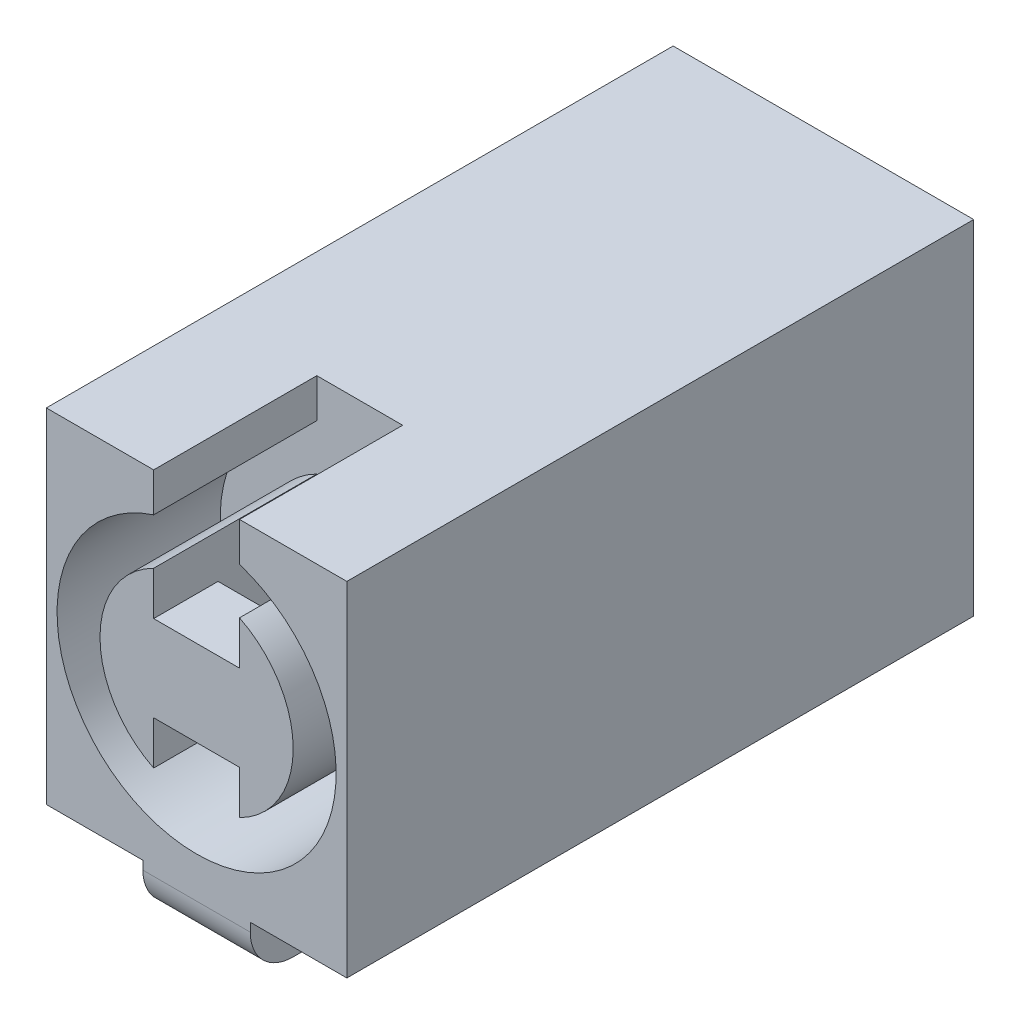
from build123d import *

# Parameters (mm, degrees)
SZKIC1_W                    = 7
SZKIC1_H                    = 14.6
DODANIE_WYCI_GNI_CIE1_DEPTH = 8
SZKIC2_W                    = 2
SZKIC2_H                    = 5
WYTNIJ_WYCI_GNI_CIE1_DEPTH  = 3.5
SZKIC7_R                    = 3.25
SZKIC7_R_2                  = 2.25
WYTNIJ_WYCI_GNI_CIE4_DEPTH  = 3.8
SZKIC10_W                   = 2
SZKIC10_H                   = 6.184658438
WYTNIJ_WYCI_GNI_CIE6_DEPTH  = 3.8
SZKIC12_W                   = 1.5
SZKIC12_H                   = 2
DODANIE_WYCI_GNI_CIE4_DEPTH = 2
SZKIC15_W                   = 2.5
SZKIC15_H                   = 4.8
DODANIE_WYCI_GNI_CIE6_DEPTH = 1.2
SZKIC16_W                   = 2
SZKIC16_H                   = 1
DODANIE_WYCI_GNI_CIE7_DEPTH = 1
ZAOKR_GLENIE2_R             = 1
SZKIC17_W                   = 2
SZKIC17_H                   = 3.8
WYTNIJ_WYCI_GNI_CIE7_DEPTH  = 2


with BuildPart() as part:
    # Szkic1 → Dodanie-wyciągnięcie1 (new body)
    with BuildSketch(Plane(origin=(0, 0, 0), x_dir=(1, 0, 0), z_dir=(0, 1, 0))):
        with Locations((3.5, 7.3)):
            Rectangle(SZKIC1_W, SZKIC1_H)
    extrude(amount=DODANIE_WYCI_GNI_CIE1_DEPTH)

    # Szkic2 → Wytnij-wyciągnięcie1 (cut)
    with BuildSketch(Plane.XZ):
        with Locations((3.5, -7.3)):
            Rectangle(SZKIC2_W, SZKIC2_H)
    extrude(amount=-WYTNIJ_WYCI_GNI_CIE1_DEPTH, mode=Mode.SUBTRACT)

    # Szkic7 → Wytnij-wyciągnięcie4 (cut)
    with BuildSketch(Plane.XY):
        with Locations((3.5, 4)):
            Circle(SZKIC7_R)
        with Locations((3.5, 4)):
            Circle(SZKIC7_R_2, mode=Mode.SUBTRACT)
    extrude(amount=-WYTNIJ_WYCI_GNI_CIE4_DEPTH, mode=Mode.SUBTRACT)

    # Szkic10 → Wytnij-wyciągnięcie6 (cut)
    with BuildSketch(Plane.XY):
        with Locations((3.5, 4)):
            Rectangle(SZKIC10_W, SZKIC10_H)
    extrude(amount=-WYTNIJ_WYCI_GNI_CIE6_DEPTH, mode=Mode.SUBTRACT)

    # Szkic12 → Dodanie-wyciągnięcie4 (add)
    with BuildSketch(Plane(origin=(2.5, 0, 0), x_dir=(0, 0, -1), z_dir=(1, 0, 0))):
        with Locations((0.75, 4)):
            Rectangle(SZKIC12_W, SZKIC12_H)
    extrude(amount=DODANIE_WYCI_GNI_CIE4_DEPTH)

    # Szkic15 → Dodanie-wyciągnięcie6 (add)
    with BuildSketch(Plane.XZ):
        with Locations((3.5, -2.4)):
            Rectangle(SZKIC15_W, SZKIC15_H)
        with Locations((3.5, -12.2)):
            Rectangle(SZKIC15_W, SZKIC15_H)
    extrude(amount=DODANIE_WYCI_GNI_CIE6_DEPTH)

    # Szkic16 → Dodanie-wyciągnięcie7 (add)
    with BuildSketch(Plane.XZ.offset(-3.5)):
        with Locations((3.5, -7.3)):
            Rectangle(SZKIC16_W, SZKIC16_H)
    extrude(amount=DODANIE_WYCI_GNI_CIE7_DEPTH)

    # Zaokrąglenie2
    zaokr_glenie2_edges = [part.edges().sort_by_distance(p)[0] for p in [
        (3.5, -1.2, -14.6),
        (3.5, -1.2, 0),
    ]]
    fillet(zaokr_glenie2_edges, radius=ZAOKR_GLENIE2_R)

    # Szkic17 → Wytnij-wyciągnięcie7 (cut)
    with BuildSketch(Plane(origin=(0, 8, 0), x_dir=(1, 0, 0), z_dir=(0, 1, 0))):
        with Locations((3.5, 1.9)):
            Rectangle(SZKIC17_W, SZKIC17_H)
    extrude(amount=-WYTNIJ_WYCI_GNI_CIE7_DEPTH, mode=Mode.SUBTRACT)


solid = part.part
